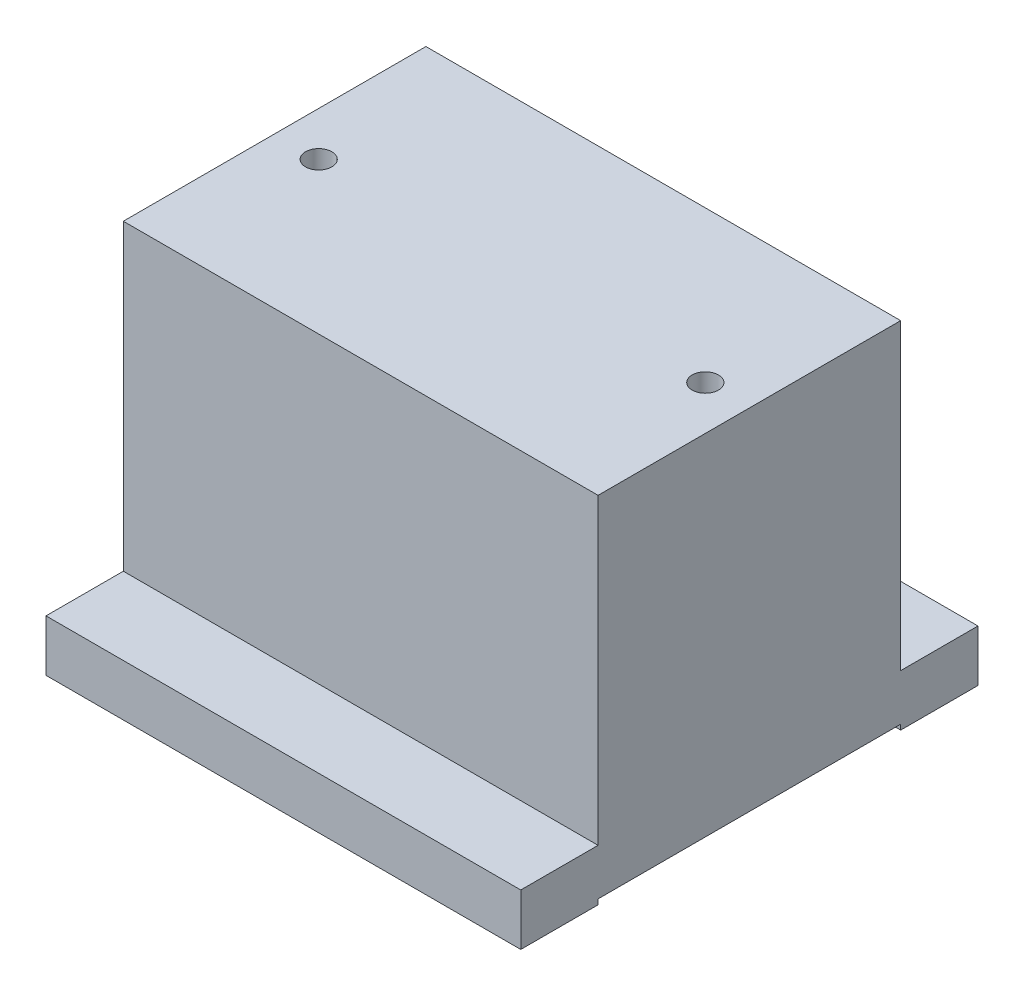
from build123d import *

# Parameters (mm, degrees)
SKETCH1_W                   = 92.1
SKETCH1_H                   = 88.7
BOSS_EXTRUDE1_DEPTH         = 10
SKETCH2_W                   = 92.1
SKETCH2_H                   = 58.7
BOSS_EXTRUDE2_DEPTH         = 58.8
SKETCH16_W                  = 92.1
SKETCH16_H                  = 58.7
CUT_EXTRUDE2_DEPTH          = 1
F_1_4_20_TAPPED_HOLE1_D     = 5.1054
F_1_4_20_TAPPED_HOLE1_DEPTH = 16.51
F_1_4_20_TAPPED_HOLE1_TIP   = 1.533816902


with BuildPart() as part:
    # Sketch1 → Boss-Extrude1 (new body)
    with BuildSketch(Plane(origin=(0, 0, 0), x_dir=(1, 0, 0), z_dir=(0, 1, 0))):
        Rectangle(SKETCH1_W, SKETCH1_H)
    extrude(amount=BOSS_EXTRUDE1_DEPTH)

    # Sketch2 → Boss-Extrude2 (add)
    with BuildSketch(Plane(origin=(0, 10, 0), x_dir=(1, 0, 0), z_dir=(0, 1, 0))):
        Rectangle(SKETCH2_W, SKETCH2_H)
    extrude(amount=BOSS_EXTRUDE2_DEPTH)

    # Sketch16 → Cut-Extrude2 (cut)
    with BuildSketch(Plane.XZ):
        Rectangle(SKETCH16_W, SKETCH16_H)
    extrude(amount=-CUT_EXTRUDE2_DEPTH, mode=Mode.SUBTRACT)

    # 1/4-20 Tapped Hole1
    with Locations(Plane(origin=(0, 68.8, 0), x_dir=(-1, 0, 0), z_dir=(0, 1, 0))):
        with Locations((37.5, 0), (-37.5, 0)):
            Hole(F_1_4_20_TAPPED_HOLE1_D / 2, depth=F_1_4_20_TAPPED_HOLE1_DEPTH)
            with Locations((0, 0, -(F_1_4_20_TAPPED_HOLE1_DEPTH + F_1_4_20_TAPPED_HOLE1_TIP / 2))):  # 118° drill point
                Cone(0, F_1_4_20_TAPPED_HOLE1_D / 2, F_1_4_20_TAPPED_HOLE1_TIP, mode=Mode.SUBTRACT)


solid = part.part
